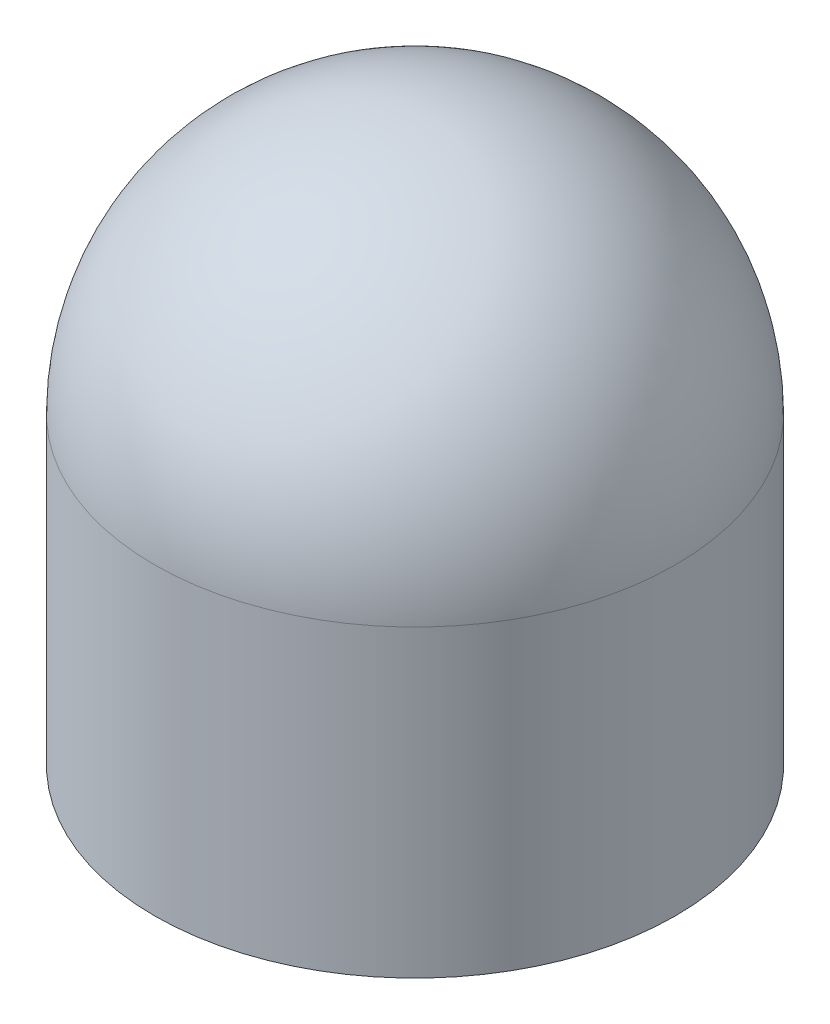
from build123d import *

# Parameters (mm, degrees)
SKETCH1_R           = 1.5
BOSS_EXTRUDE1_DEPTH = 1.75
DOME1_FACE_RADIUS   = 1.5
DOME1_HEIGHT        = 1.5


with BuildPart() as part:
    # Sketch1 → Boss-Extrude1 (new body)
    with BuildSketch(Plane(origin=(0, 0, 0), x_dir=(1, 0, 0), z_dir=(0, 1, 0))):
        Circle(SKETCH1_R)
    extrude(amount=BOSS_EXTRUDE1_DEPTH)

    # Dome1: a dome of height H over a round flat face of radius A is a cap of a sphere of radius (A * A + H * H) / (2 * H)
    dome1_r = (DOME1_FACE_RADIUS * DOME1_FACE_RADIUS + DOME1_HEIGHT * DOME1_HEIGHT) / (2 * DOME1_HEIGHT)
    dome1_base = Plane((0, 1.75, 0), z_dir=(0, 1, 0))
    with Locations(dome1_base.offset(DOME1_HEIGHT - dome1_r)):
        dome1_ball = Sphere(dome1_r, mode=Mode.PRIVATE)
    add(split(dome1_ball, bisect_by=dome1_base, keep=Keep.TOP, mode=Mode.PRIVATE))


solid = part.part
